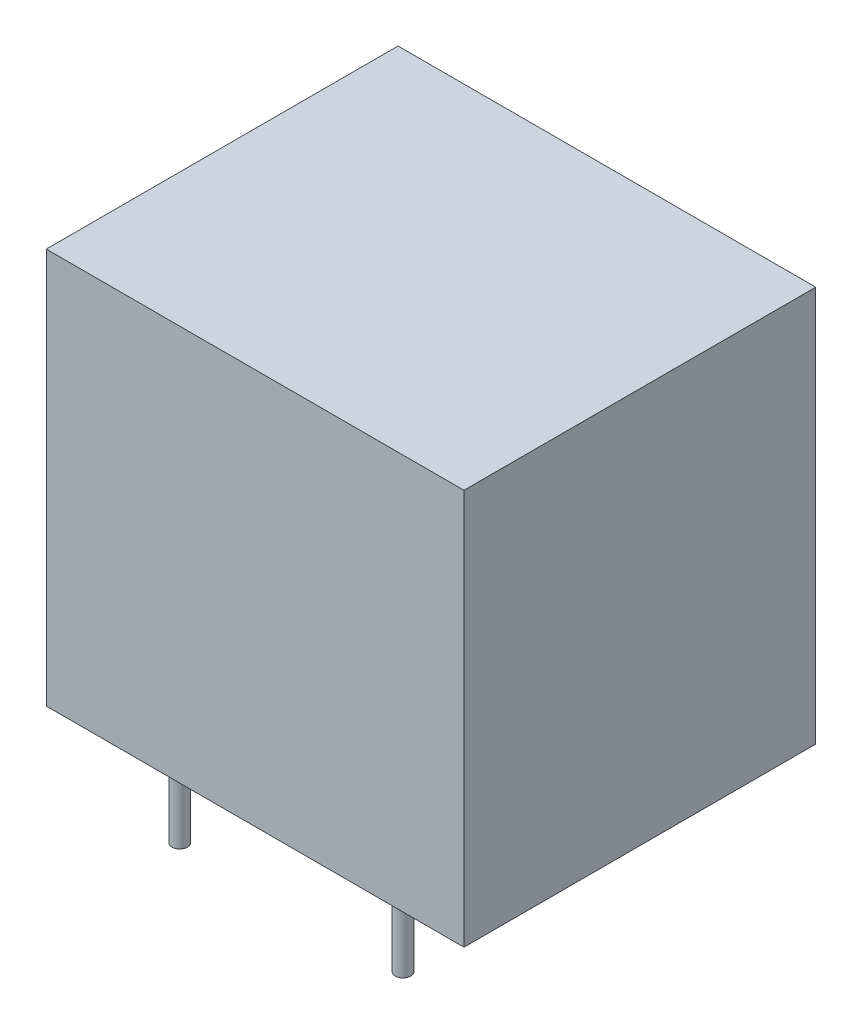
from build123d import *

# Parameters (mm, degrees)
CROQUIS1_W              = 19
CROQUIS1_H              = 16
SALIENTE_EXTRUIR1_DEPTH = 18
CROQUIS2_R              = 0.35
SALIENTE_EXTRUIR2_DEPTH = 4


with BuildPart() as part:
    # Croquis1 → Saliente-Extruir1 (new body)
    with BuildSketch(Plane(origin=(0, 0, 0), x_dir=(1, 0, 0), z_dir=(0, 1, 0))):
        Rectangle(CROQUIS1_W, CROQUIS1_H)
    extrude(amount=SALIENTE_EXTRUIR1_DEPTH)

    # Croquis2 → Saliente-Extruir2 (add)
    with BuildSketch(Plane.XZ):
        with Locations((-5.08, 6.35)):
            Circle(CROQUIS2_R)
        with Locations((5.08, 6.35)):
            Circle(CROQUIS2_R)
        with Locations((5.08, -6.35)):
            Circle(CROQUIS2_R)
        with Locations((-5.08, -6.35)):
            Circle(CROQUIS2_R)
    extrude(amount=SALIENTE_EXTRUIR2_DEPTH)


solid = part.part
